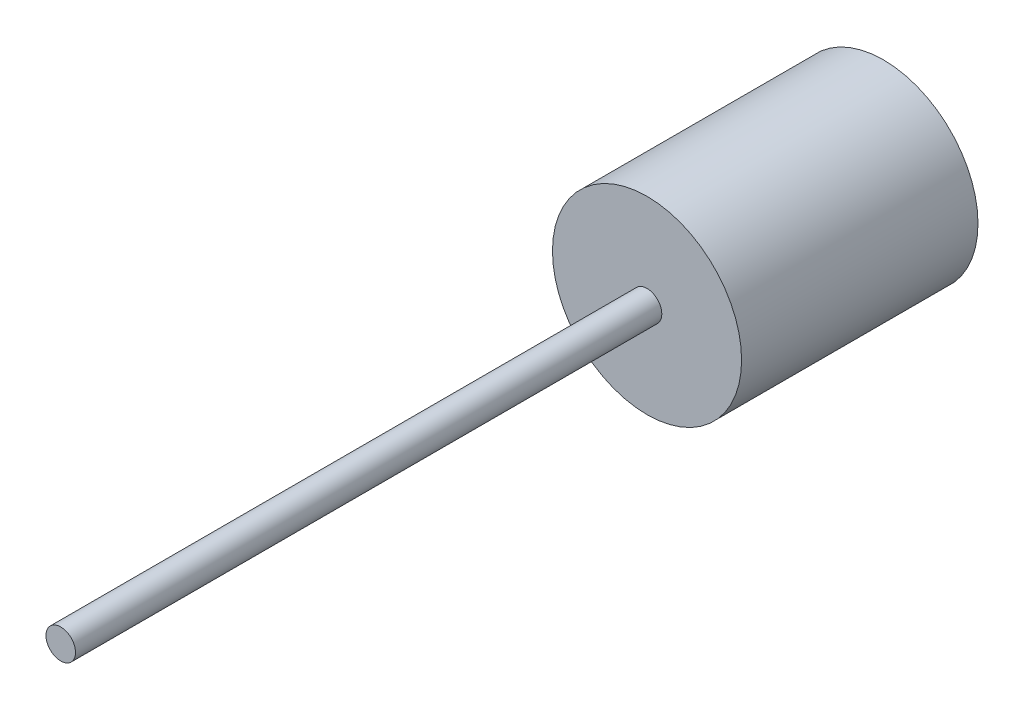
from build123d import *

# Parameters (mm, degrees)
SKETCH1_R           = 12.7
BOSS_EXTRUDE1_DEPTH = 31.75
SKETCH2_R           = 1.984375
BOSS_EXTRUDE2_DEPTH = 78.74


with BuildPart() as part:
    # Sketch1 → Boss-Extrude1 (new body)
    with BuildSketch(Plane.XY):
        Circle(SKETCH1_R)
    extrude(amount=BOSS_EXTRUDE1_DEPTH)

    # Sketch2 → Boss-Extrude2 (add)
    with BuildSketch(Plane.XY.offset(31.75)):
        Circle(SKETCH2_R)
    extrude(amount=BOSS_EXTRUDE2_DEPTH)


solid = part.part
